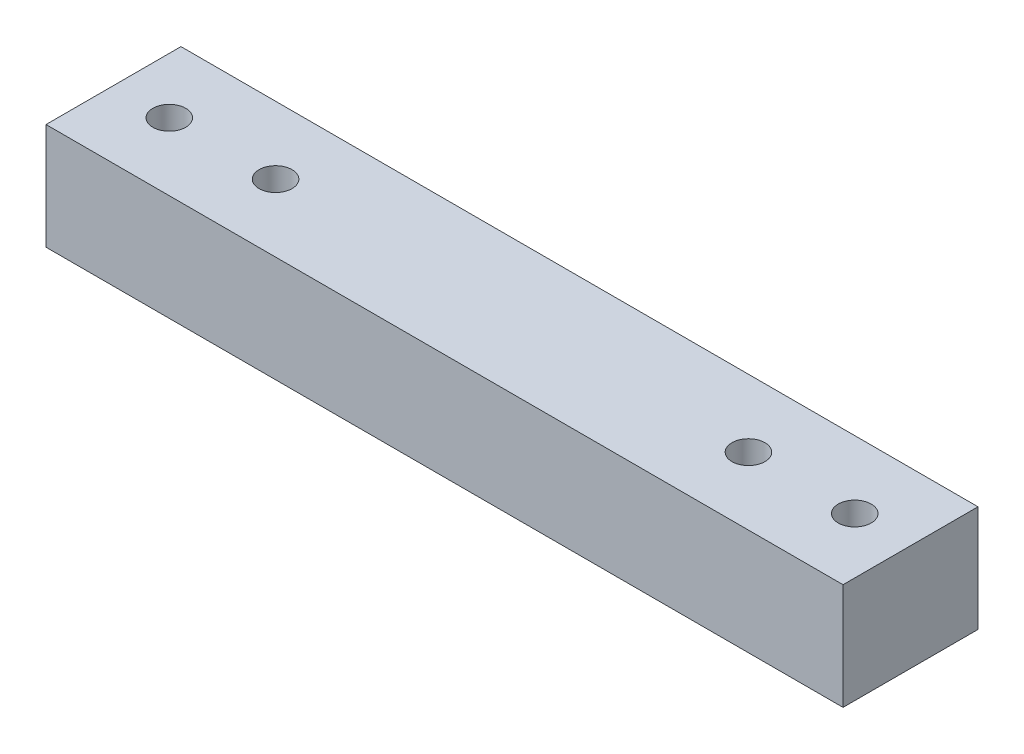
from build123d import *

# Parameters (mm, degrees)
SKETCH1_W           = 75
SKETCH1_H           = 12.7
BOSS_EXTRUDE1_DEPTH = 10
SKETCH2_R           = 1.55
CUT_EXTRUDE1_DEPTH  = 11


with BuildPart() as part:
    # Sketch1 → Boss-Extrude1 (new body)
    with BuildSketch(Plane(origin=(0, 0, 0), x_dir=(1, 0, 0), z_dir=(0, 1, 0))):
        Rectangle(SKETCH1_W, SKETCH1_H)
    extrude(amount=BOSS_EXTRUDE1_DEPTH)

    # Sketch2 → Cut-Extrude1 (cut, through all)
    with BuildSketch(Plane(origin=(0, 10, 0), x_dir=(1, 0, 0), z_dir=(0, 1, 0))):
        with Locations((32.25, 0)):
            Circle(SKETCH2_R)
        with Locations((22.25, 0)):
            Circle(SKETCH2_R)
        with Locations((-32.25, 0)):
            Circle(SKETCH2_R)
        with Locations((-22.25, 0)):
            Circle(SKETCH2_R)
    extrude(amount=-CUT_EXTRUDE1_DEPTH, mode=Mode.SUBTRACT)


solid = part.part
